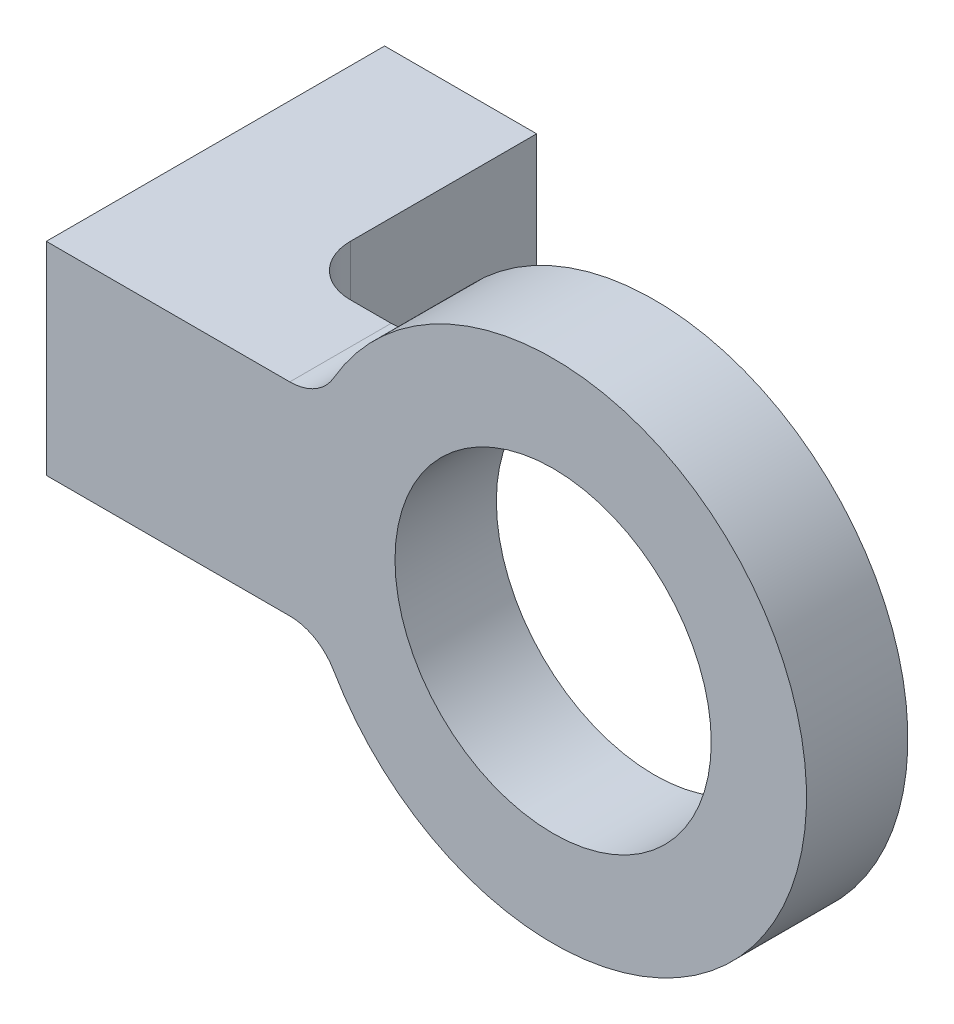
from build123d import *

# Parameters (mm, degrees)
SKETCH1_R                 = 9.906
BOSS_EXTRUDE1_DEPTH       = 6.35
SKETCH2_W                 = 9.525
SKETCH2_H                 = 12.7
BOSS_EXTRUDE2_DEPTH       = 21.193
F_8_32_TAPPED_HOLE1_D     = 3.4544
F_8_32_TAPPED_HOLE1_DEPTH = 16.85544
F_8_32_TAPPED_HOLE1_TIP   = 1.037806461
FILLET1_R                 = 3.175


with BuildPart() as part:
    # Sketch1 → Boss-Extrude1 (new body)
    with BuildSketch(Plane.XY):
        with BuildLine():
            Line((7.675322169, 12.7), (0, 12.7))
            Line((0, 12.7), (0, 0))
            Line((0, 0), (7.675322169, 0))
            ThreePointArc((7.675322169, 0), (38.1, 6.35), (7.675322169, 12.7))
        make_face()
        with Locations((22.225, 6.35)):
            Circle(SKETCH1_R, mode=Mode.SUBTRACT)
    extrude(amount=BOSS_EXTRUDE1_DEPTH)

    # Sketch2 → Boss-Extrude2 (add)
    with BuildSketch(Plane.XY.offset(6.35)):
        with Locations((-4.7625, 6.35)):
            Rectangle(SKETCH2_W, SKETCH2_H)
    extrude(amount=-BOSS_EXTRUDE2_DEPTH)

    # #8-32 Tapped Hole1
    with Locations(Plane(origin=(0, 0, -14.843), x_dir=(-1, 0, 0), z_dir=(0, 0, -1))):
        with Locations((4.7625, 6.35)):
            Hole(F_8_32_TAPPED_HOLE1_D / 2, depth=F_8_32_TAPPED_HOLE1_DEPTH)
            with Locations((0, 0, -(F_8_32_TAPPED_HOLE1_DEPTH + F_8_32_TAPPED_HOLE1_TIP / 2))):  # 118° drill point
                Cone(0, F_8_32_TAPPED_HOLE1_D / 2, F_8_32_TAPPED_HOLE1_TIP, mode=Mode.SUBTRACT)

    # Fillet1
    fillet1_edges = [part.edges().sort_by_distance(p)[0] for p in [
        (0, 6.35, 0),
        (7.675322169, 12.7, 3.175),
        (7.675322169, 0, 3.175),
    ]]
    fillet(fillet1_edges, radius=FILLET1_R)


solid = part.part
